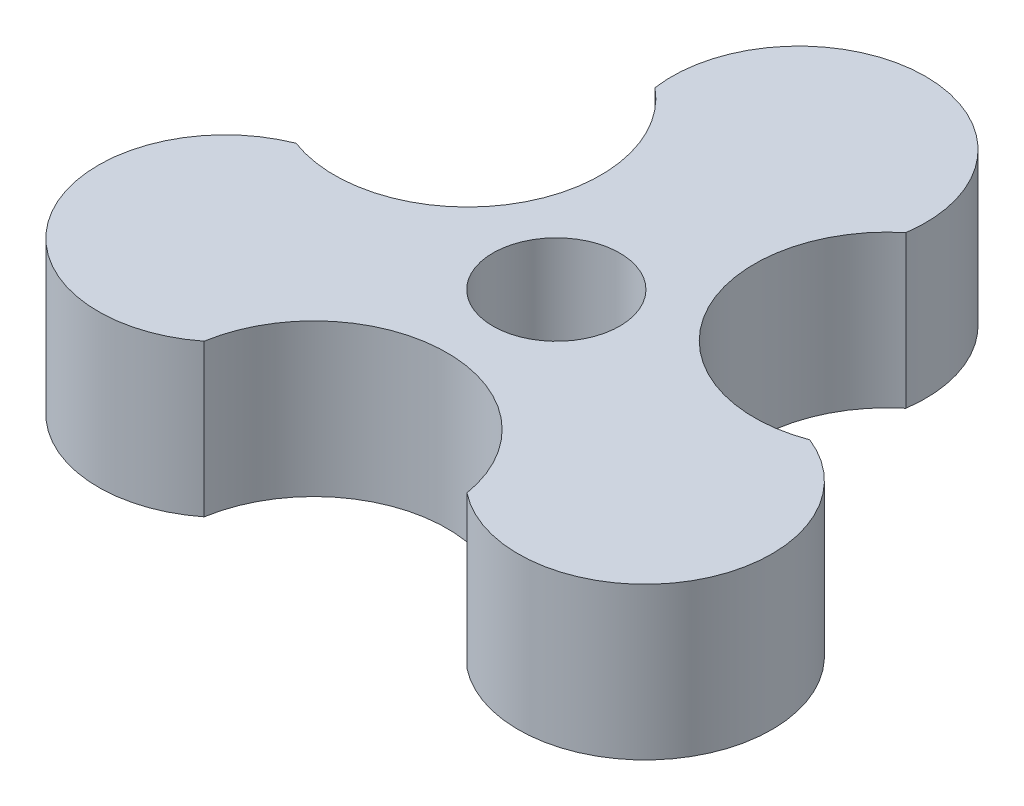
from build123d import *

# Parameters (mm, degrees)
BOSS_EXTRUDE1_DEPTH = 6
SKETCH3_R           = 2.5
CUT_EXTRUDE1_DEPTH  = 8


with BuildPart() as part:
    # Sketch2 → Boss-Extrude1 (new body)
    with BuildSketch(Plane(origin=(0, 0, 0), x_dir=(1, 0, 0), z_dir=(0, 1, 0))):
        with BuildLine():
            ThreePointArc((10.127144448, -0.134021967), (3.73256949, 2.155), (4.947505796, 8.837375343))
            ThreePointArc((4.947505796, 8.837375343), (0, 14.56), (-4.947505796, 8.837375343))
            ThreePointArc((-4.947505796, 8.837375343), (-3.73256949, 2.155), (-10.127144448, -0.134021967))
            ThreePointArc((-10.127144448, -0.134021967), (-12.609329879, -7.28), (-5.179638652, -8.703353377))
            ThreePointArc((-5.179638652, -8.703353377), (0, -4.31), (5.179638652, -8.703353377))
            ThreePointArc((5.179638652, -8.703353377), (12.609329879, -7.28), (10.127144448, -0.134021967))
        make_face()
    extrude(amount=BOSS_EXTRUDE1_DEPTH)

    # Sketch3 → Cut-Extrude1 (cut)
    with BuildSketch(Plane(origin=(0, 6, 0), x_dir=(1, 0, 0), z_dir=(0, 1, 0))):
        Circle(SKETCH3_R)
    extrude(amount=-CUT_EXTRUDE1_DEPTH, mode=Mode.SUBTRACT)


solid = part.part
